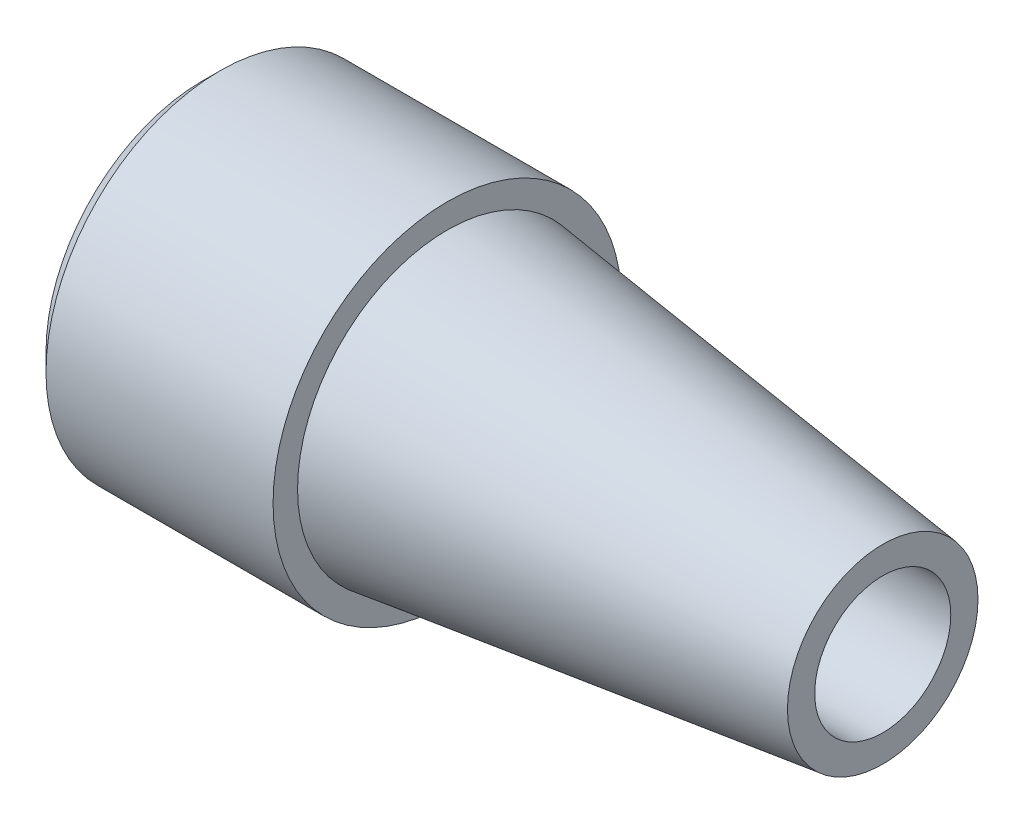
from build123d import *

# Parameters (mm, degrees)
SKETCH_4_R      = 32
SKETCH_4_R_2    = 27.5
EXTRUDE_1_DEPTH = 45
CHAMFER_1_SIZE  = 3.2875


with BuildPart() as part:
    # Эскиз1 → Повернуть1 (revolve)
    with BuildSketch(Plane.XY):
        Polygon((-125, 27.5), (-80, 27.5), (0, 17.5), (0, 12.5), (-77.272727273, 12.5), (-125, 25), align=None)
    revolve(axis=Axis((0, 0, 0), (-1, 0, 0)))

    # Эскиз4 → Бобышка-Вытянуть1 (add)
    with BuildSketch(Plane.ZY.offset(125)):
        Circle(SKETCH_4_R)
        Circle(SKETCH_4_R_2, mode=Mode.SUBTRACT)
    extrude(amount=-EXTRUDE_1_DEPTH)

    # Фаска1
    chamfer_1_edges = [part.edges().sort_by_distance(p)[0] for p in [
        (-125, 0, -32),
    ]]
    chamfer(chamfer_1_edges, length=CHAMFER_1_SIZE)


solid = part.part
